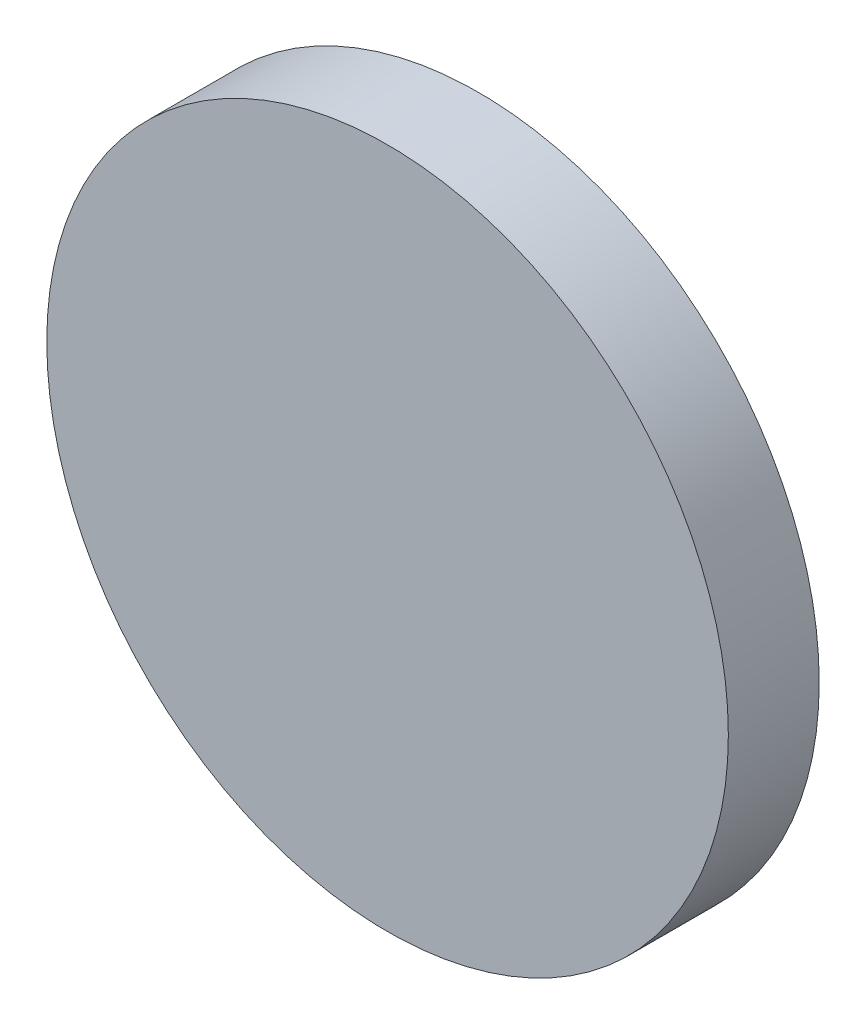
from build123d import *

# Parameters (mm, degrees)
CROQUIS1_R              = 7.5
SALIENTE_EXTRUIR1_DEPTH = 2
CROQUIS2_R              = 5.015
CORTAR_EXTRUIR1_DEPTH   = 0.5


with BuildPart() as part:
    # Croquis1 → Saliente-Extruir1 (new body)
    with BuildSketch(Plane.XY):
        Circle(CROQUIS1_R)
    extrude(amount=SALIENTE_EXTRUIR1_DEPTH)

    # Croquis2 → Cortar-Extruir1 (cut)
    with BuildSketch(Plane(origin=(0, 0, 0), x_dir=(-1, 0, 0), z_dir=(0, 0, -1))):
        Circle(CROQUIS2_R)
    extrude(amount=-CORTAR_EXTRUIR1_DEPTH, mode=Mode.SUBTRACT)


solid = part.part
